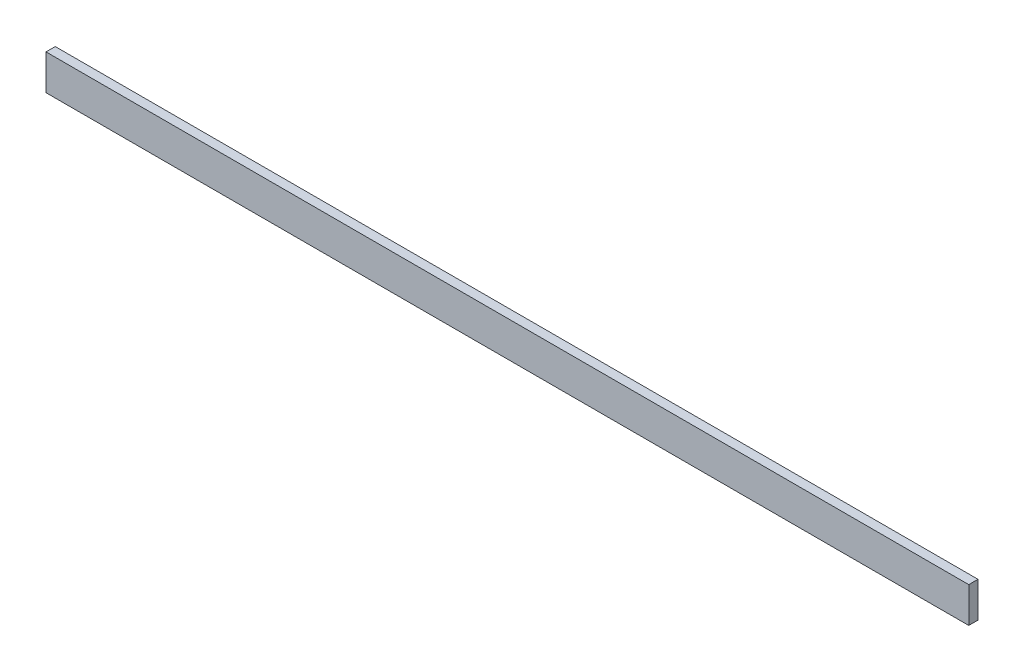
from build123d import *

# Parameters (mm, degrees)
SKETCH1_W           = 998.75708883
SKETCH1_H           = 38.292622135
BOSS_EXTRUDE1_DEPTH = 10


with BuildPart() as part:
    # Sketch1 → Boss-Extrude1 (new body)
    with BuildSketch(Plane.XY):
        with Locations((499.378544415, 19.146311068)):
            Rectangle(SKETCH1_W, SKETCH1_H)
    extrude(amount=BOSS_EXTRUDE1_DEPTH)


solid = part.part
